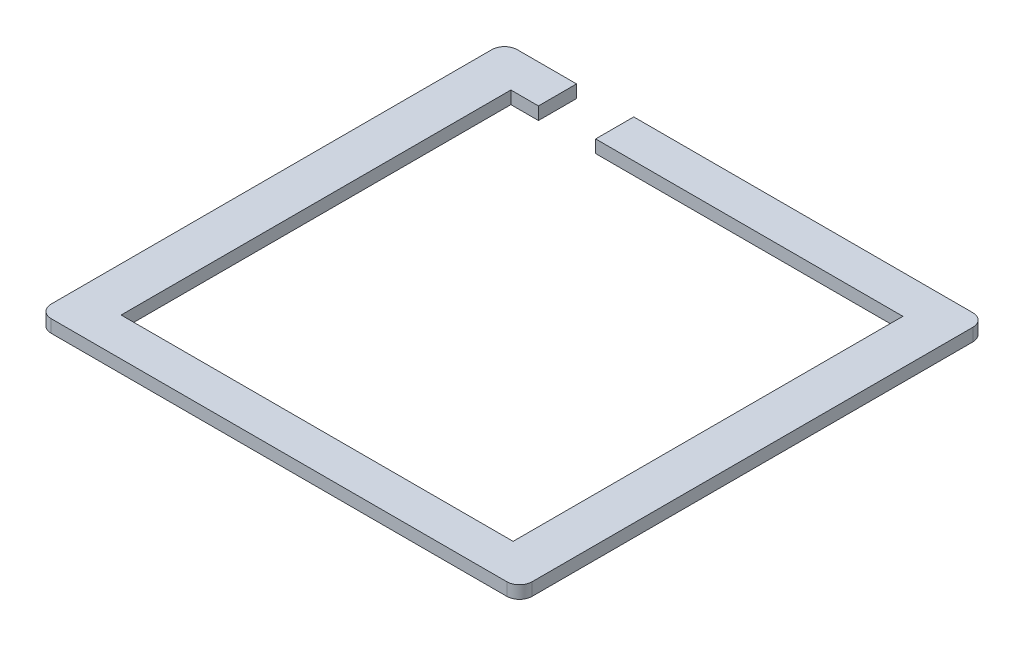
from build123d import *

# Parameters (mm, degrees)
SKETCH_1_W          = 61.702142611
SKETCH_1_H          = 61.347239899
EXTRUDE_1_DEPTH     = 2
SKETCH_2_W          = 9
SKETCH_2_H          = 6
CUT_EXTRUDE_1_DEPTH = 2


with BuildPart() as part:
    # 草图1 → 凸台-拉伸1 (new body)
    with BuildSketch(Plane(origin=(-129.641159043, -2421.788142989, -243.940490516), x_dir=(1, 0, 0), z_dir=(0, 1, 0))):
        with BuildLine():
            Line((-116.231072015, -154.924864972), (-44.528929404, -154.924864972))
            ThreePointArc((-44.528929404, -154.924864972), (-43.114715842, -155.510651409), (-42.528929404, -156.924864972))
            Line((-42.528929404, -156.924864972), (-42.528929404, -226.272104871))
            ThreePointArc((-42.528929404, -226.272104871), (-43.114715842, -227.686318433), (-44.528929404, -228.272104871))
            Line((-44.528929404, -228.272104871), (-116.231072015, -228.272104871))
            ThreePointArc((-116.231072015, -228.272104871), (-117.645285578, -227.686318433), (-118.231072015, -226.272104871))
            Line((-118.231072015, -226.272104871), (-118.231072015, -156.924864972))
            ThreePointArc((-118.231072015, -156.924864972), (-117.645285578, -155.510651409), (-116.231072015, -154.924864972))
        make_face()
        with Locations((-80.38000071, -191.598484922)):
            Rectangle(SKETCH_1_W, SKETCH_1_H, mode=Mode.SUBTRACT)
    extrude(amount=EXTRUDE_1_DEPTH)

    # 草图2 → 切除-拉伸1 (cut)
    with BuildSketch(Plane(origin=(0, -2419.788142989, 0), x_dir=(1, 0, 0), z_dir=(0, 1, 0))):
        with Locations((-232.033164197, 86.015625544)):
            Rectangle(SKETCH_2_W, SKETCH_2_H)
    extrude(amount=-CUT_EXTRUDE_1_DEPTH, mode=Mode.SUBTRACT)


solid = part.part
